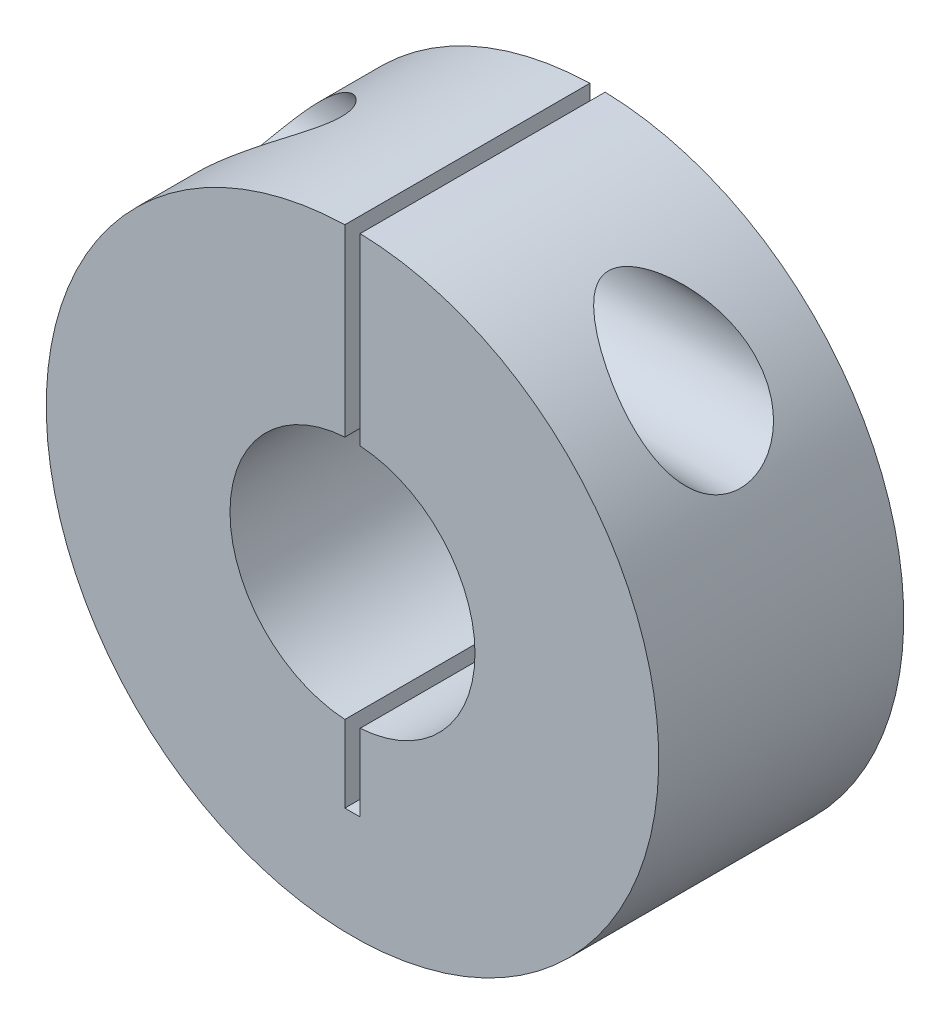
from build123d import *

# Parameters (mm, degrees)
SKETCH1_R               = 10
SKETCH1_R_2             = 4
BOSS_EXTRUDE1_DEPTH     = 8
SKETCH2_W               = 0.5
SKETCH2_H               = 17
CUT_EXTRUDE1_DEPTH      = 8
SKETCH3_R               = 2
CUT_EXTRUDE2_DEPTH      = 11
CUT_EXTRUDE2_DEPTH_BACK = 11


with BuildPart() as part:
    # Sketch1 → Boss-Extrude1 (new body)
    with BuildSketch(Plane.XY):
        Circle(SKETCH1_R)
        Circle(SKETCH1_R_2, mode=Mode.SUBTRACT)
    extrude(amount=BOSS_EXTRUDE1_DEPTH)

    # Sketch2 → Cut-Extrude1 (cut)
    with BuildSketch(Plane.XY.offset(8)):
        with Locations((0, 2)):
            Rectangle(SKETCH2_W, SKETCH2_H)
    extrude(amount=-CUT_EXTRUDE1_DEPTH, mode=Mode.SUBTRACT)

    # Sketch3 → Cut-Extrude2 (cut, two sides)
    with BuildSketch(Plane(origin=(0, 0, 0), x_dir=(0, 0, -1), z_dir=(1, 0, 0))) as cut_extrude2_sk:
        with Locations((-4, 7)):
            Circle(SKETCH3_R)
    extrude(amount=CUT_EXTRUDE2_DEPTH, mode=Mode.SUBTRACT)
    extrude(cut_extrude2_sk.sketch, amount=-CUT_EXTRUDE2_DEPTH_BACK, mode=Mode.SUBTRACT)


solid = part.part
